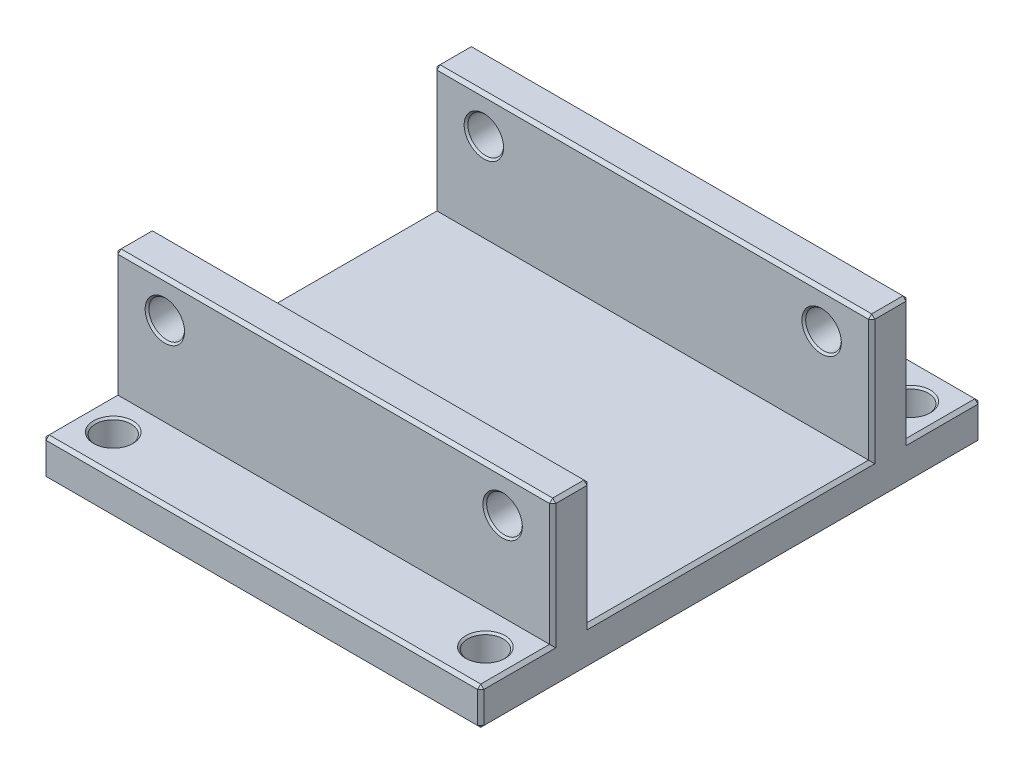
from build123d import *

# Parameters (mm, degrees)
SKETCH_1_W                     = 70
SKETCH_1_H                     = 80
EXTRUDE_1_DEPTH                = 26
SKETCH_2_W                     = 11.5
SKETCH_2_H                     = 20
CUT_EXTRUDE_1_DEPTH            = 71
SKETCH_3_W                     = 45
SKETCH_3_H                     = 20
CUT_EXTRUDE_2_DEPTH            = 71
SKETCH_4_W                     = 11.5
SKETCH_4_H                     = 20
CUT_EXTRUDE_3_DEPTH            = 71
F_5_7_5_7_DIAMETER_HOLE1_D     = 5.7
F_5_7_5_7_DIAMETER_HOLE1_DEPTH = 6
F_5_7_5_7_DIAMETER_HOLE2_D     = 5.7
F_5_7_5_7_DIAMETER_HOLE2_DEPTH = 26
F_5_7_5_7_DIAMETER_HOLE3_D     = 5.7
F_5_7_5_7_DIAMETER_HOLE3_DEPTH = 17.5
F_5_7_5_7_DIAMETER_HOLE4_D     = 5.7
F_5_7_5_7_DIAMETER_HOLE4_DEPTH = 6
F_5_7_5_7_DIAMETER_HOLE5_D     = 5.7
F_5_7_5_7_DIAMETER_HOLE5_DEPTH = 68.5
F_5_7_5_7_DIAMETER_HOLE6_D     = 5.7
F_5_7_5_7_DIAMETER_HOLE6_DEPTH = 17.5
CHAMFER_1_SIZE                 = 0.3
CHAMFER_2_SIZE                 = 0.5


with BuildPart() as part:
    # 스케치1 → 보스-돌출1 (new body)
    with BuildSketch(Plane(origin=(0, 26, 0), x_dir=(1, 0, 0), z_dir=(0, 1, 0))):
        Rectangle(SKETCH_1_W, SKETCH_1_H)
    extrude(amount=-EXTRUDE_1_DEPTH)

    # 스케치2 → 컷-돌출1 (cut, through all)
    with BuildSketch(Plane(origin=(35, 0, 0), x_dir=(0, 0, -1), z_dir=(1, 0, 0))):
        with Locations((-34.25, 16)):
            Rectangle(SKETCH_2_W, SKETCH_2_H)
    extrude(amount=-CUT_EXTRUDE_1_DEPTH, mode=Mode.SUBTRACT)

    # 스케치3 → 컷-돌출2 (cut, through all)
    with BuildSketch(Plane(origin=(35, 0, 0), x_dir=(0, 0, -1), z_dir=(1, 0, 0))):
        with Locations((0, 16)):
            Rectangle(SKETCH_3_W, SKETCH_3_H)
    extrude(amount=-CUT_EXTRUDE_2_DEPTH, mode=Mode.SUBTRACT)

    # 스케치4 → 컷-돌출3 (cut, through all)
    with BuildSketch(Plane(origin=(35, 0, 0), x_dir=(0, 0, -1), z_dir=(1, 0, 0))):
        with Locations((34.25, 16)):
            Rectangle(SKETCH_4_W, SKETCH_4_H)
    extrude(amount=-CUT_EXTRUDE_3_DEPTH, mode=Mode.SUBTRACT)

    # Ø5.7 (5.7) Diameter Hole1
    with Locations(Plane(origin=(0, 6, 0), x_dir=(1, 0, 0), z_dir=(0, 1, 0))):
        with Locations((-29.75, 34)):
            Hole(F_5_7_5_7_DIAMETER_HOLE1_D / 2, depth=F_5_7_5_7_DIAMETER_HOLE1_DEPTH)

    # Ø5.7 (5.7) Diameter Hole2
    with Locations(Plane(origin=(0, 0, 0), x_dir=(-1, 0, 0), z_dir=(0, -1, 0))):
        with Locations((-29.75, -34), (-29.75, 34), (29.75, -34)):
            Hole(F_5_7_5_7_DIAMETER_HOLE2_D / 2, depth=F_5_7_5_7_DIAMETER_HOLE2_DEPTH)

    # Ø5.7 (5.7) Diameter Hole3
    with Locations(Plane.XY.offset(-22.5)):
        with Locations((-27, 20.1)):
            Hole(F_5_7_5_7_DIAMETER_HOLE3_D / 2, depth=F_5_7_5_7_DIAMETER_HOLE3_DEPTH)

    # Ø5.7 (5.7) Diameter Hole4
    with Locations(Plane(origin=(0, 0, -28.5), x_dir=(-1, 0, 0), z_dir=(0, 0, -1))):
        with Locations((-27, 20.1)):
            Hole(F_5_7_5_7_DIAMETER_HOLE4_D / 2, depth=F_5_7_5_7_DIAMETER_HOLE4_DEPTH)

    # Ø5.7 (5.7) Diameter Hole5
    with Locations(Plane.XY.offset(28.5)):
        with Locations((-27, 20.1)):
            Hole(F_5_7_5_7_DIAMETER_HOLE5_D / 2, depth=F_5_7_5_7_DIAMETER_HOLE5_DEPTH)

    # Ø5.7 (5.7) Diameter Hole6
    with Locations(Plane(origin=(0, 0, 22.5), x_dir=(-1, 0, 0), z_dir=(0, 0, -1))):
        with Locations((-27, 20.1)):
            Hole(F_5_7_5_7_DIAMETER_HOLE6_D / 2, depth=F_5_7_5_7_DIAMETER_HOLE6_DEPTH)

    # 모따기1
    chamfer_1_edges = [part.edges().sort_by_distance(p)[0] for p in [
        (-24.15, 20.1, 22.5),
        (-24.15, 20.1, 28.5),
        (24.15, 20.1, 28.5),
        (24.15, 20.1, 22.5),
        (-26.9, 6, -34),
        (-26.9, 0, -34),
        (-32.6, 6, 34),
        (-32.6, 0, 34),
        (26.9, 6, -34),
        (26.9, 0, -34),
        (26.9, 6, 34),
        (26.9, 0, 34),
        (-24.15, 20.1, -28.5),
        (-24.15, 20.1, -22.5),
        (24.15, 20.1, -28.5),
        (24.15, 20.1, -22.5),
    ]]
    chamfer(chamfer_1_edges, length=CHAMFER_1_SIZE)

    # 모따기2
    chamfer_2_edges = [part.edges().sort_by_distance(p)[0] for p in [
        (-35, 0, 0),
        (35, 26, 25.5),
        (0, 0, 40),
        (-35, 6, 34.25),
        (0, 6, 40),
        (-35, 16, 28.5),
        (0, 26, 28.5),
        (35, 6, 34.25),
        (35, 16, 28.5),
        (35, 26, -25.5),
        (-35, 26, 25.5),
        (0, 26, 22.5),
        (-35, 16, -22.5),
        (0, 26, -22.5),
        (-35, 6, 0),
        (-35, 16, 22.5),
        (35, 16, 22.5),
        (35, 6, 0),
        (35, 16, -22.5),
        (-35, 26, -25.5),
        (35, 0, 0),
        (0, 26, -28.5),
        (-35, 6, -34.25),
        (0, 6, -40),
        (-35, 16, -28.5),
        (35, 16, -28.5),
        (35, 6, -34.25),
        (35, 3, 40),
        (-35, 3, 40),
        (-35, 3, -40),
        (35, 3, -40),
        (0, 0, -40),
    ]]
    chamfer(chamfer_2_edges, length=CHAMFER_2_SIZE)


solid = part.part
